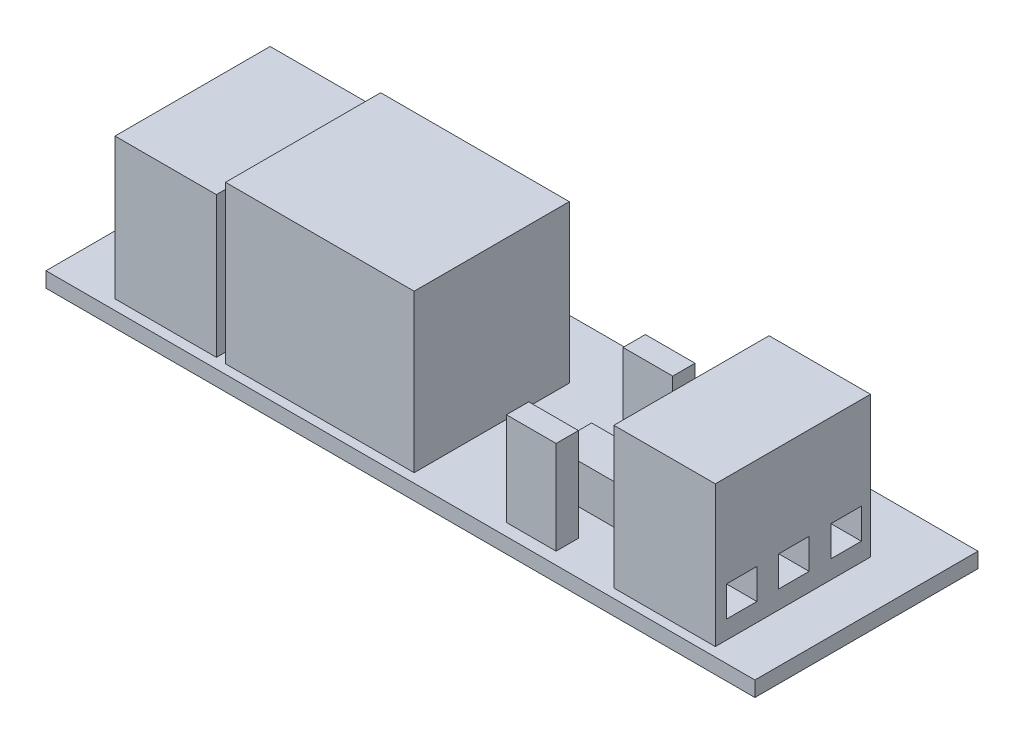
from build123d import *

# Parameters (mm, degrees)
SKETCH1_W           = 69.9
SKETCH1_H           = 22
BOSS_EXTRUDE1_DEPTH = 1.5
BOSS_EXTRUDE2_START = -1.5
SKETCH2_W           = 10
SKETCH2_H           = 15.3
BOSS_EXTRUDE2_DEPTH = 15.4
BOSS_EXTRUDE3_START = -1.5
SKETCH2_3_W         = 18.6
SKETCH2_3_H         = 15.3
BOSS_EXTRUDE3_DEPTH = 17
SKETCH3_W           = 3
SKETCH3_H           = 3
CUT_EXTRUDE1_DEPTH  = 8
SKETCH4_W           = 3
SKETCH4_H           = 3
CUT_EXTRUDE2_DEPTH  = 8
BOSS_EXTRUDE5_START = -1.5
SKETCH5_W           = 4.9
SKETCH5_H           = 2.2
BOSS_EXTRUDE5_DEPTH = 10.7
BOSS_EXTRUDE6_START = -1.5
SKETCH5_3_W         = 6.1
SKETCH5_3_H         = 3.9
BOSS_EXTRUDE6_DEPTH = 5.4
SKETCH6_W           = 53
SKETCH6_H           = 14.6
BOSS_EXTRUDE7_DEPTH = 1


with BuildPart() as part:
    # Sketch1 → Boss-Extrude1 (new body)
    with BuildSketch(Plane(origin=(0, 0, 0), x_dir=(1, 0, 0), z_dir=(0, 1, 0))):
        with Locations((9.6, 7.6)):
            Rectangle(SKETCH1_W, SKETCH1_H)
    extrude(amount=BOSS_EXTRUDE1_DEPTH)

    # Sketch2 → Boss-Extrude2 (add)
    with BuildSketch(Plane(origin=(0, 1.5, 0), x_dir=(1, 0, 0), z_dir=(0, 1, 0)).offset(BOSS_EXTRUDE2_START)):
        with Locations((-14.55, 5.25)):
            Rectangle(SKETCH2_W, SKETCH2_H)
        with Locations((34.75, 5.15)):
            Rectangle(SKETCH2_W, SKETCH2_H)
    extrude(amount=BOSS_EXTRUDE2_DEPTH)

    # Sketch2_3 → Boss-Extrude3 (add)
    with BuildSketch(Plane(origin=(0, 1.5, 0), x_dir=(1, 0, 0), z_dir=(0, 1, 0)).offset(BOSS_EXTRUDE3_START)):
        with Locations((0.75, 5.15)):
            Rectangle(SKETCH2_3_W, SKETCH2_3_H)
    extrude(amount=BOSS_EXTRUDE3_DEPTH)

    # Sketch3 → Cut-Extrude1 (cut)
    with BuildSketch(Plane.ZY.offset(19.55)):
        with Locations((-10.4, 4.8)):
            Rectangle(SKETCH3_W, SKETCH3_H)
        with Locations((-5.25, 4.8)):
            Rectangle(SKETCH3_W, SKETCH3_H)
        with Locations((-0.1, 4.8)):
            Rectangle(SKETCH3_W, SKETCH3_H)
    extrude(amount=-CUT_EXTRUDE1_DEPTH, mode=Mode.SUBTRACT)

    # Sketch4 → Cut-Extrude2 (cut)
    with BuildSketch(Plane(origin=(39.75, 0, 0), x_dir=(0, 0, -1), z_dir=(1, 0, 0))):
        with Locations((10.4, 4.8)):
            Rectangle(SKETCH4_W, SKETCH4_H)
        with Locations((5.25, 4.8)):
            Rectangle(SKETCH4_W, SKETCH4_H)
        with Locations((0.1, 4.8)):
            Rectangle(SKETCH4_W, SKETCH4_H)
    extrude(amount=-CUT_EXTRUDE2_DEPTH, mode=Mode.SUBTRACT)

    # Sketch5 → Boss-Extrude5 (add)
    with BuildSketch(Plane(origin=(0, 1.5, 0), x_dir=(1, 0, 0), z_dir=(0, 1, 0)).offset(BOSS_EXTRUDE5_START)):
        with Locations((21.3, 10.4)):
            Rectangle(SKETCH5_W, SKETCH5_H)
        with Locations((21.3, -1.1)):
            Rectangle(SKETCH5_W, SKETCH5_H)
    extrude(amount=BOSS_EXTRUDE5_DEPTH)

    # Sketch5_3 → Boss-Extrude6 (add)
    with BuildSketch(Plane(origin=(0, 1.5, 0), x_dir=(1, 0, 0), z_dir=(0, 1, 0)).offset(BOSS_EXTRUDE6_START)):
        with Locations((21.5, 4.65)):
            Rectangle(SKETCH5_3_W, SKETCH5_3_H)
    extrude(amount=BOSS_EXTRUDE6_DEPTH)

    # Sketch6 → Boss-Extrude7 (add)
    with BuildSketch(Plane.XZ):
        with Locations((9.45, -5.1)):
            Rectangle(SKETCH6_W, SKETCH6_H)
    extrude(amount=BOSS_EXTRUDE7_DEPTH)


solid = part.part
